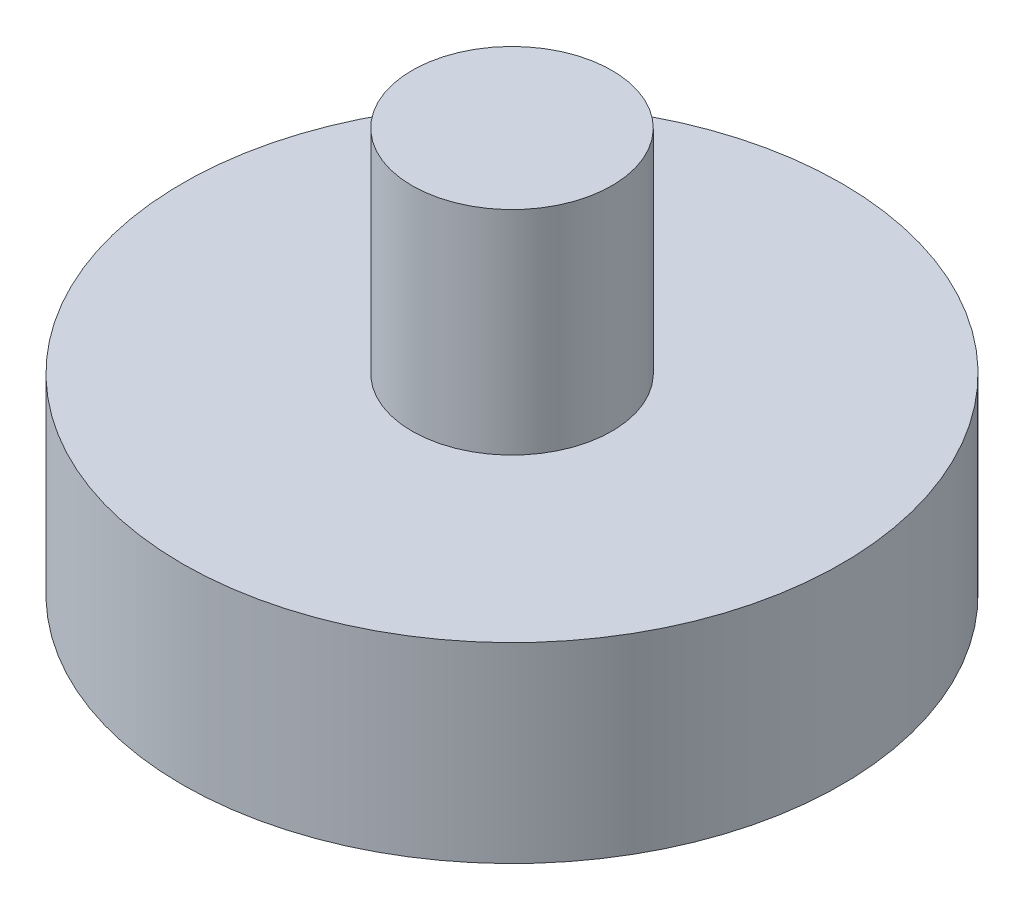
from build123d import *

# Parameters (mm, degrees)
IZIM1_R                     = 7.75
Y_KSEKLIK_EKSTR_ZYON1_DEPTH = 4.5
IZIM2_R                     = 2.35
Y_KSEKLIK_EKSTR_ZYON2_DEPTH = 5
IZIM3_R                     = 3.1
KES_EKSTR_ZYON1_DEPTH       = 3.5


with BuildPart() as part:
    # Çizim1 → Yükseklik-Ekstrüzyon1 (new body)
    with BuildSketch(Plane(origin=(0, 0, 0), x_dir=(1, 0, 0), z_dir=(0, 1, 0))):
        Circle(IZIM1_R)
    extrude(amount=Y_KSEKLIK_EKSTR_ZYON1_DEPTH)

    # Çizim2 → Yükseklik-Ekstrüzyon2 (add)
    with BuildSketch(Plane(origin=(0, 4.5, 0), x_dir=(1, 0, 0), z_dir=(0, 1, 0))):
        Circle(IZIM2_R)
    extrude(amount=Y_KSEKLIK_EKSTR_ZYON2_DEPTH)

    # Çizim3 → Kes-Ekstrüzyon1 (cut)
    with BuildSketch(Plane.XZ):
        Circle(IZIM3_R)
    extrude(amount=-KES_EKSTR_ZYON1_DEPTH, mode=Mode.SUBTRACT)


solid = part.part
